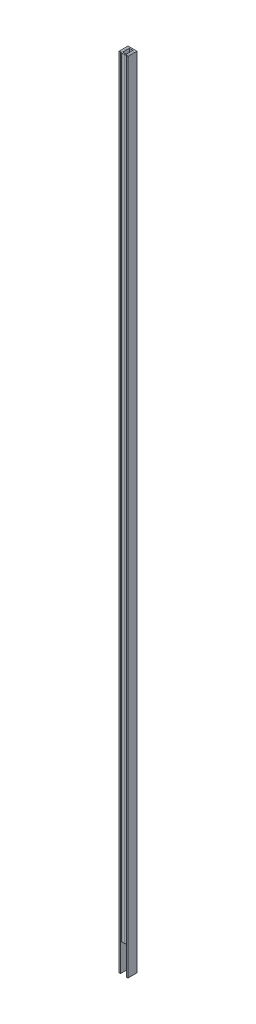
from build123d import *

# Parameters (mm, degrees)
BOSS_EXTRUDE1_DEPTH = 1260
SKETCH2_R           = 3
FIXING_DEPTH        = 3
SKETCH4_W           = 5
SKETCH4_H           = 5
LED_DEPTH           = 3
LPATTERN1_COUNT     = 72
LPATTERN1_PITCH     = 16.6
DIFFUSER_DEPTH      = 1215


with BuildPart() as part:
    # Sketch1 → Boss-Extrude1 (new body)
    with BuildSketch(Plane(origin=(0, 0, 0), x_dir=(1, 0, 0), z_dir=(0, 1, 0))):
        Polygon((-5, 0), (-7, 0), (-7, 14), (7, 14), (7, 0), (5, 0), (5, 12), (-5, 12), align=None)
    extrude(amount=BOSS_EXTRUDE1_DEPTH)

    # Sketch2 → Fixing (cut, through all)
    with BuildSketch(Plane.XY.offset(-12)):
        with Locations((0, 46)):
            Circle(SKETCH2_R)
        with Locations((0, 11)):
            Circle(SKETCH2_R)
    extrude(amount=-FIXING_DEPTH, mode=Mode.SUBTRACT)

    # Sketch4 → LED (add)
    with BuildSketch(Plane.XY.offset(-12)):
        with Locations((0, 72)):
            Rectangle(SKETCH4_W, SKETCH4_H)
    led = extrude(amount=LED_DEPTH)

    # LPattern1: LED ×72
    with Locations(*[(0, i * LPATTERN1_PITCH, 0) for i in range(1, LPATTERN1_COUNT)]):
        add(led)


with BuildPart() as body_2:
    # Sketch3 → Diffuser (new body)
    with BuildSketch(Plane(origin=(0, 1260, 0), x_dir=(1, 0, 0), z_dir=(0, 1, 0))):
        with BuildLine():
            Line((-5, 12), (-3, 12))
            Line((-3, 12), (-3, 2.5))
            ThreePointArc((-3, 2.5), (-2.707106781, 1.792893219), (-2, 1.5))
            Line((-2, 1.5), (2, 1.5))
            ThreePointArc((2, 1.5), (2.707106781, 1.792893219), (3, 2.5))
            Line((3, 2.5), (3, 12))
            Line((3, 12), (5, 12))
            Line((5, 12), (5, 2.5))
            ThreePointArc((5, 2.5), (4.121320344, 0.378679656), (2, -0.5))
            Line((2, -0.5), (-2, -0.5))
            ThreePointArc((-2, -0.5), (-4.121320344, 0.378679656), (-5, 2.5))
            Line((-5, 2.5), (-5, 12))
        make_face()
    extrude(amount=-DIFFUSER_DEPTH)


solid = Compound([part.part, body_2.part])
